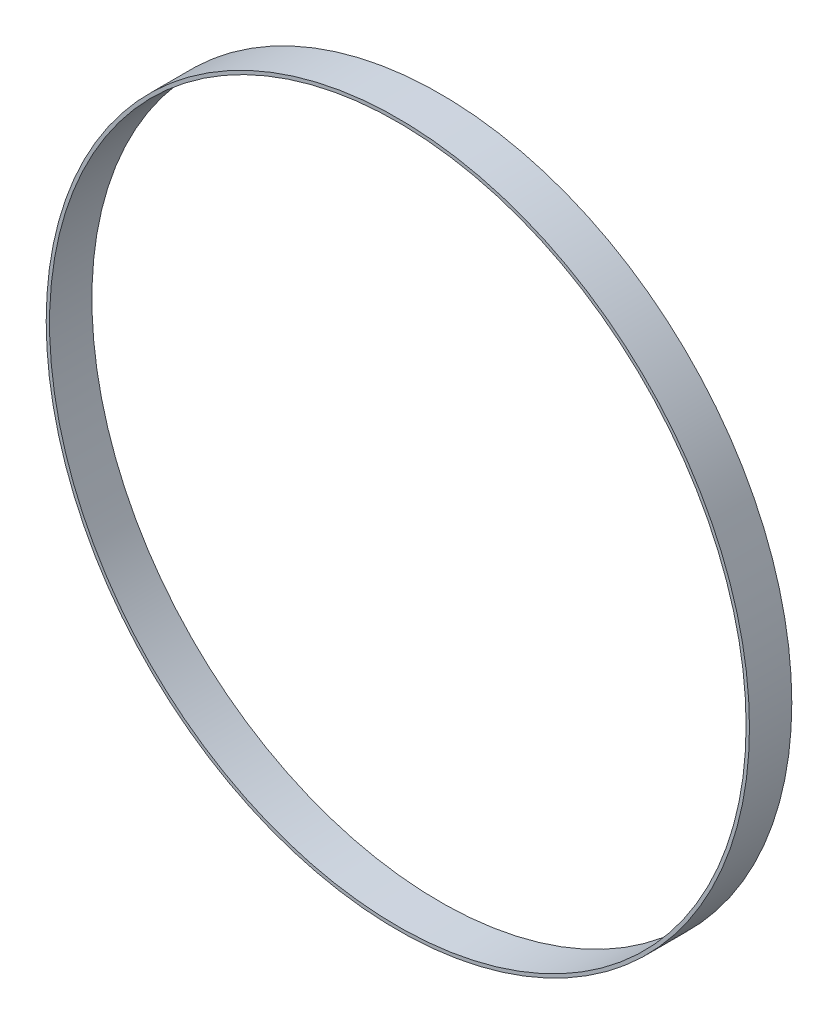
from build123d import *

# Parameters (mm, degrees)
SKETCH1_R           = 83.05
SKETCH1_R_2         = 82.25625
BOSS_EXTRUDE1_DEPTH = 10


with BuildPart() as part:
    # Sketch1 → Boss-Extrude1 (new body)
    with BuildSketch(Plane.XY):
        Circle(SKETCH1_R)
        Circle(SKETCH1_R_2, mode=Mode.SUBTRACT)
    extrude(amount=BOSS_EXTRUDE1_DEPTH)


solid = part.part
